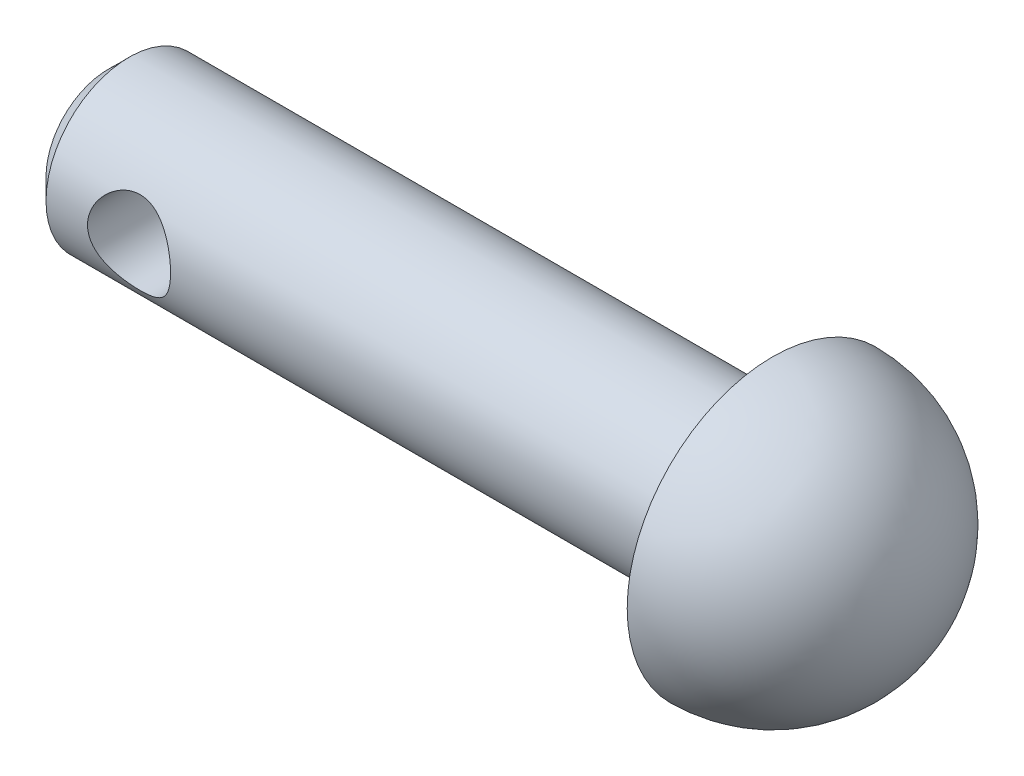
from build123d import *

# Parameters (mm, degrees)
CHAMFER1_SIZE           = 0.5
SKETCH2_R               = 1
CUT_EXTRUDE1_DEPTH      = 4.5
CUT_EXTRUDE1_DEPTH_BACK = 4.5


with BuildPart() as part:
    # Sketch1 → Revolve1 (revolve)
    with BuildSketch(Plane.XY):
        with BuildLine():
            Line((-6.989590942, 0), (-6.989590942, 2))
            Line((-6.989590942, 2), (9.010409058, 2))
            Line((9.010409058, 2), (9.010409058, 3.5))
            ThreePointArc((9.010409058, 3.5), (11.485282792, 2.474873734), (12.510409058, 0))
            Line((12.510409058, 0), (-6.989590942, 0))
        make_face()
    revolve(axis=Axis((-10.070672023, 0, 0), (1, 0, 0)))

    # Chamfer1
    chamfer1_edges = [part.edges().sort_by_distance(p)[0] for p in [
        (-6.989590942, -2, 0),
    ]]
    chamfer(chamfer1_edges, length=CHAMFER1_SIZE)

    # Sketch2 → Cut-Extrude1 (cut, two sides)
    with BuildSketch(Plane.XY) as cut_extrude1_sk:
        with Locations((-4.489590942, 0)):
            Circle(SKETCH2_R)
    extrude(amount=CUT_EXTRUDE1_DEPTH, mode=Mode.SUBTRACT)
    extrude(cut_extrude1_sk.sketch, amount=-CUT_EXTRUDE1_DEPTH_BACK, mode=Mode.SUBTRACT)


solid = part.part
